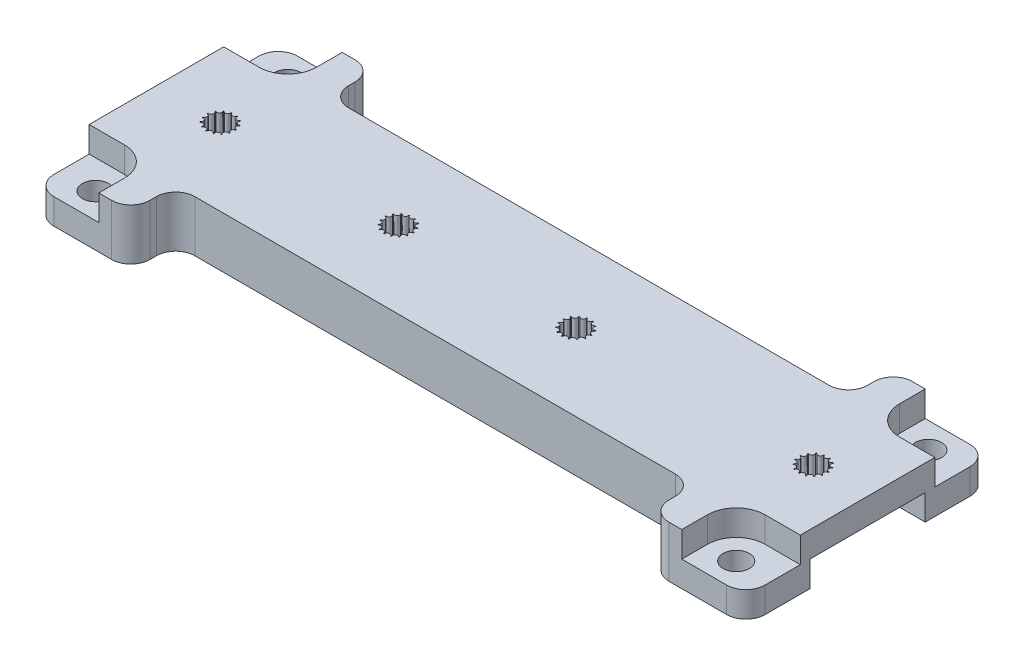
from build123d import *

# Parameters (mm, degrees)
SKETCH1_W               = 127
SKETCH1_H               = 38
BOSS_EXTRUDE1_DEPTH     = 8
SKETCH2_R               = 2.05
CUT_EXTRUDE1_DEPTH      = 10
CUT_EXTRUDE2_DEPTH      = 4
MIRROR2_COPY_1_SKETCH_R = 2.05
MIRROR2_COPY_1_DEPTH    = 10
MIRROR2_COPY_2_DEPTH    = 4
SKETCH5_W               = 127
SKETCH5_H               = 44
SKETCH5_R               = 2.05
BOSS_EXTRUDE2_DEPTH     = 4
SKETCH6_W               = 146.022926602
SKETCH6_H               = 82.651118602
SKETCH6_W_2             = 111
SKETCH6_H_2             = 44
CUT_EXTRUDE3_DEPTH      = 12
CUT_EXTRUDE4_DEPTH      = 12
LPATTERN1_COUNT         = 11
LPATTERN1_PITCH         = 9.25
SKETCH8_W               = 101
SKETCH8_H               = 18
SKETCH8_W_2             = 4.159836495
SKETCH8_W_3             = 3
SKETCH8_W_4             = 3.884566757
CUT_EXTRUDE5_DEPTH      = 4
SKETCH9_W               = 81
SKETCH9_H               = 10
CUT_EXTRUDE6_DEPTH      = 10
SKETCH10_W              = 142.25201053
SKETCH10_H              = 55.562925419
SKETCH10_W_2            = 127
SKETCH10_H_2            = 38
CUT_EXTRUDE7_DEPTH      = 10
FILLET1_R               = 3


with BuildPart() as part:
    # Sketch1 → Boss-Extrude1 (new body)
    with BuildSketch(Plane(origin=(0, 0, 0), x_dir=(1, 0, 0), z_dir=(0, 1, 0))):
        with Locations((53.5, 9)):
            Rectangle(SKETCH1_W, SKETCH1_H)
    extrude(amount=BOSS_EXTRUDE1_DEPTH)

    # Sketch2 → Cut-Extrude1 (cut)
    with BuildSketch(Plane(origin=(0, 8, 0), x_dir=(1, 0, 0), z_dir=(0, 1, 0))):
        with Locations((3.5, 24)):
            Circle(SKETCH2_R)
    cut_extrude1 = extrude(amount=-CUT_EXTRUDE1_DEPTH, mode=Mode.SUBTRACT)

    # Sketch3 → Cut-Extrude2 (cut)
    with BuildSketch(Plane(origin=(0, 8, 0), x_dir=(1, 0, 0), z_dir=(0, 1, 0))):
        with BuildLine():
            Line((8, 24), (8, 28))
            Line((8, 28), (-10, 28))
            Line((-10, 28), (-10, 19.5))
            Line((-10, 19.5), (3.5, 19.5))
            ThreePointArc((3.5, 19.5), (6.681980515, 20.818019485), (8, 24))
        make_face()
    cut_extrude2 = extrude(amount=-CUT_EXTRUDE2_DEPTH, mode=Mode.SUBTRACT)

    # Mirror1: Cut-Extrude1, Cut-Extrude2 across plane
    add(cut_extrude1.mirror(Plane.ZY.offset(-53.5)), mode=Mode.SUBTRACT)
    add(cut_extrude2.mirror(Plane.ZY.offset(-53.5)), mode=Mode.SUBTRACT)

    # Mirror2: Cut-Extrude2, Cut-Extrude1 across plane
    add(cut_extrude2.mirror(Plane.XY.offset(-9)), mode=Mode.SUBTRACT)
    add(cut_extrude1.mirror(Plane.XY.offset(-9)), mode=Mode.SUBTRACT)

    # Mirror2 copy 1 sketch → Mirror2 copy 1 (cut)
    with BuildSketch(Plane(origin=(107, 8, -18), x_dir=(-1, 0, 0), z_dir=(0, 1, 0))):
        with Locations((3.5, 24)):
            Circle(MIRROR2_COPY_1_SKETCH_R)
    extrude(amount=-MIRROR2_COPY_1_DEPTH, mode=Mode.SUBTRACT)

    # Mirror2 copy 2 sketch → Mirror2 copy 2 (cut)
    with BuildSketch(Plane(origin=(107, 8, -18), x_dir=(-1, 0, 0), z_dir=(0, 1, 0))):
        with BuildLine():
            Line((8, 24), (8, 28))
            Line((8, 28), (-10, 28))
            Line((-10, 28), (-10, 19.5))
            Line((-10, 19.5), (3.5, 19.5))
            ThreePointArc((3.5, 19.5), (6.681980515, 20.818019485), (8, 24))
        make_face()
    extrude(amount=-MIRROR2_COPY_2_DEPTH, mode=Mode.SUBTRACT)

    # Sketch5 → Boss-Extrude2 (add)
    with BuildSketch(Plane.XZ):
        with Locations((53.5, -9)):
            Rectangle(SKETCH5_W, SKETCH5_H)
        with Locations((103.5, 6)):
            Circle(SKETCH5_R, mode=Mode.SUBTRACT)
        with Locations((103.5, -24)):
            Circle(SKETCH5_R, mode=Mode.SUBTRACT)
        with Locations((3.5, 6)):
            Circle(SKETCH5_R, mode=Mode.SUBTRACT)
        with Locations((3.5, -24)):
            Circle(SKETCH5_R, mode=Mode.SUBTRACT)
    extrude(amount=-BOSS_EXTRUDE2_DEPTH)

    # Sketch6 → Cut-Extrude3 (cut, symmetric)
    with BuildSketch(Plane(origin=(0, 4, 0), x_dir=(1, 0, 0), z_dir=(0, 1, 0))):
        with Locations((52.618218697, 9.314399754)):
            Rectangle(SKETCH6_W, SKETCH6_H)
        with Locations((53.5, 9)):
            Rectangle(SKETCH6_W_2, SKETCH6_H_2, mode=Mode.SUBTRACT)
    extrude(amount=CUT_EXTRUDE3_DEPTH, both=True, mode=Mode.SUBTRACT)

    # Sketch7 → Cut-Extrude4 (cut, symmetric)
    with BuildSketch(Plane(origin=(0, 8, 0), x_dir=(1, 0, 0), z_dir=(0, 1, 0))):
        with BuildLine():
            ThreePointArc((10.160667609, 8.372293474), (9.839865506, 8.806622343), (10.243959363, 9.164761577))
            ThreePointArc((10.243959363, 9.164761577), (10.237674265, 9.235189042), (10.229179325, 9.305384245))
            ThreePointArc((10.229179325, 9.305384245), (9.759454555, 9.57168144), (9.982944313, 10.063217688))
            ThreePointArc((9.982944313, 10.063217688), (9.948557159, 10.125), (9.912245684, 10.185671305))
            ThreePointArc((9.912245684, 10.185671305), (9.374817927, 10.237891622), (9.379060176, 10.777833803))
            ThreePointArc((9.379060176, 10.777833803), (9.322516818, 10.820288237), (9.264667392, 10.860945025))
            ThreePointArc((9.264667392, 10.860945025), (8.75246279, 10.690059097), (8.536724007, 11.185046302))
            ThreePointArc((8.536724007, 11.185046302), (8.467801304, 11.200832102), (8.398416619, 11.214444444))
            ThreePointArc((8.398416619, 11.214444444), (8, 10.85), (7.601583381, 11.214444444))
            ThreePointArc((7.601583381, 11.214444444), (7.532198696, 11.200832102), (7.463275993, 11.185046302))
            ThreePointArc((7.463275993, 11.185046302), (7.479414078, 11.121153089), (7.484842553, 11.05547728))
            ThreePointArc((7.484842553, 11.05547728), (7.185331413, 10.668305497), (6.735332608, 10.860945025))
            ThreePointArc((6.735332608, 10.860945025), (6.677483182, 10.820288237), (6.620939824, 10.777833803))
            ThreePointArc((6.620939824, 10.777833803), (6.700218564, 10.651820533), (6.727924143, 10.505543864))
            ThreePointArc((6.727924143, 10.505543864), (6.50671462, 10.147725523), (6.087754316, 10.185671305))
            ThreePointArc((6.087754316, 10.185671305), (6.051442841, 10.125), (6.017055687, 10.063217688))
            ThreePointArc((6.017055687, 10.063217688), (6.193869104, 9.915772772), (6.260122838, 9.695288237))
            ThreePointArc((6.260122838, 9.695288237), (6.109400931, 9.382461716), (5.770820675, 9.305384245))
            ThreePointArc((5.770820675, 9.305384245), (5.762325735, 9.235189042), (5.756040637, 9.164761577))
            ThreePointArc((5.756040637, 9.164761577), (6.042937532, 9.049867127), (6.162325735, 8.764810958))
            ThreePointArc((6.162325735, 8.764810958), (6.071196794, 8.510648276), (5.839332391, 8.372293474))
            ThreePointArc((5.839332391, 8.372293474), (5.860122838, 8.304711763), (5.883026546, 8.237816691))
            ThreePointArc((5.883026546, 8.237816691), (6.266656087, 8.212169481), (6.451442841, 7.875))
            ThreePointArc((6.451442841, 7.875), (6.40640772, 7.690609287), (6.281443165, 7.547738864))
            ThreePointArc((6.281443165, 7.547738864), (6.327924143, 7.494456136), (6.376056398, 7.442660224))
            ThreePointArc((6.376056398, 7.442660224), (6.817892025, 7.554258631), (7.077483182, 7.179711763))
            ThreePointArc((7.077483182, 7.179711763), (7.063028211, 7.073151777), (7.020708029, 6.974293398))
            ThreePointArc((7.020708029, 6.974293398), (7.084842553, 6.94452272), (7.149880851, 6.916781953))
            ThreePointArc((7.149880851, 6.916781953), (7.591666595, 7.194722659), (7.932198696, 6.799167898))
            ThreePointArc((7.932198696, 6.799167898), (7.931473708, 6.775095823), (7.929301372, 6.751111007))
            ThreePointArc((7.929301372, 6.751111007), (8, 6.75), (8.070698628, 6.751111007))
            ThreePointArc((8.070698628, 6.751111007), (8.384636628, 7.190426939), (8.850119149, 6.916781953))
            ThreePointArc((8.850119149, 6.916781953), (8.915157447, 6.94452272), (8.979291971, 6.974293398))
            ThreePointArc((8.979291971, 6.974293398), (9.087402717, 7.50331856), (9.623943602, 7.442660224))
            ThreePointArc((9.623943602, 7.442660224), (9.672075857, 7.494456136), (9.718556835, 7.547738864))
            ThreePointArc((9.718556835, 7.547738864), (9.602146997, 8.075), (10.116973454, 8.237816691))
            ThreePointArc((10.116973454, 8.237816691), (10.139877162, 8.304711763), (10.160667609, 8.372293474))
        make_face()
    cut_extrude4 = extrude(amount=CUT_EXTRUDE4_DEPTH, both=True, mode=Mode.SUBTRACT)

    # LPattern1: Cut-Extrude4 ×11, 7 skipped
    with Locations(*[(i * LPATTERN1_PITCH, 0, 0) for i in range(1, LPATTERN1_COUNT) if i not in (1, 2, 4, 5, 7, 8, 9)]):
        add(cut_extrude4, mode=Mode.SUBTRACT)

    # Sketch8 → Cut-Extrude5 (cut)
    with BuildSketch(Plane.XZ):
        with Locations((53.5, -9)):
            Rectangle(SKETCH8_W, SKETCH8_H)
        with Locations((109.079918248, -9)):
            Rectangle(SKETCH8_W_2, SKETCH8_H)
        with Locations((105.5, -9)):
            Rectangle(SKETCH8_W_3, SKETCH8_H)
        with Locations((-1.942283379, -9)):
            Rectangle(SKETCH8_W_4, SKETCH8_H)
        with Locations((1.5, -9)):
            Rectangle(SKETCH8_W_3, SKETCH8_H)
    extrude(amount=-CUT_EXTRUDE5_DEPTH, mode=Mode.SUBTRACT)

    # Sketch9 → Cut-Extrude6 (cut, symmetric)
    with BuildSketch(Plane(origin=(0, 4, 0), x_dir=(1, 0, 0), z_dir=(0, 1, 0))):
        with Locations((53.5, 26)):
            Rectangle(SKETCH9_W, SKETCH9_H)
    cut_extrude6 = extrude(amount=CUT_EXTRUDE6_DEPTH, both=True, mode=Mode.SUBTRACT)

    # Mirror3: Cut-Extrude6 across plane
    add(cut_extrude6.mirror(Plane.XY.offset(-9)), mode=Mode.SUBTRACT)

    # Sketch10 → Cut-Extrude7 (cut)
    with BuildSketch(Plane(origin=(0, 4, 0), x_dir=(1, 0, 0), z_dir=(0, 1, 0))):
        with Locations((54.116206045, 11.344142116)):
            Rectangle(SKETCH10_W, SKETCH10_H)
        with Locations((53.5, 9)):
            Rectangle(SKETCH10_W_2, SKETCH10_H_2, mode=Mode.SUBTRACT)
    extrude(amount=-CUT_EXTRUDE7_DEPTH, mode=Mode.SUBTRACT)

    # Fillet1
    fillet1_edges = [part.edges().sort_by_distance(p)[0] for p in [
        (13, 4, 3),
        (94, 4, 3),
        (109, 2, -28),
        (109, 2, 10),
        (-2, 2, 10),
        (-2, 2, -28),
        (13, 4, -28),
        (94, 4, -28),
        (94, 4, -21),
        (13, 4, -21),
        (13, 4, 10),
        (94, 4, 10),
    ]]
    fillet(fillet1_edges, radius=FILLET1_R)


solid = part.part
